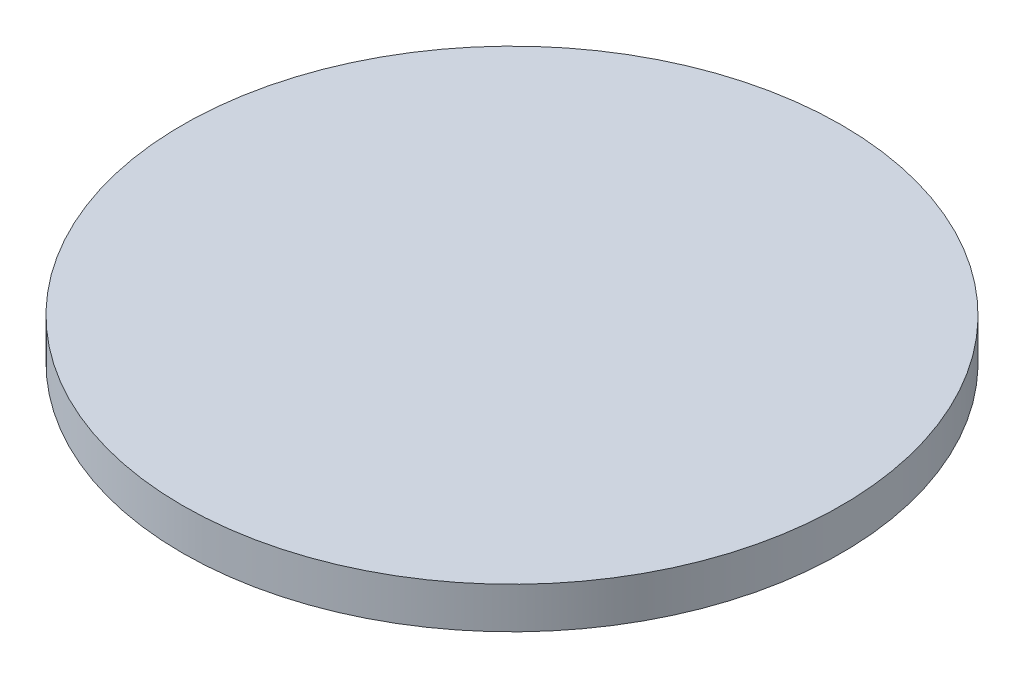
from build123d import *

# Parameters (mm, degrees)
SKETCH1_R           = 152.4
BOSS_EXTRUDE1_DEPTH = 19.05


with BuildPart() as part:
    # Sketch1 → Boss-Extrude1 (new body)
    with BuildSketch(Plane(origin=(0, 0, 0), x_dir=(1, 0, 0), z_dir=(0, 1, 0))):
        Circle(SKETCH1_R)
    extrude(amount=BOSS_EXTRUDE1_DEPTH)


solid = part.part
